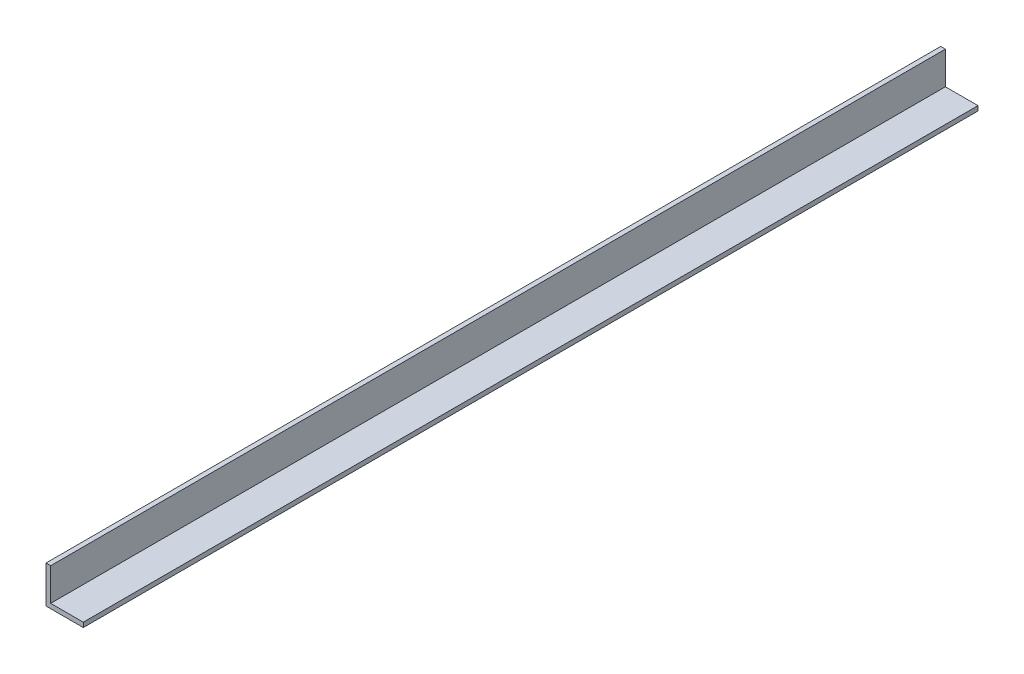
from build123d import *

# Parameters (mm, degrees)
BOSS_EXTRUDE1_DEPTH = 304.8


with BuildPart() as part:
    # Sketch1 → Boss-Extrude1 (new body, symmetric)
    with BuildSketch(Plane.XY):
        Polygon((0, 25.4), (0, 0), (25.4, 0), (25.4, 3.175), (3.175, 3.175), (3.175, 25.4), align=None)
    extrude(amount=BOSS_EXTRUDE1_DEPTH, both=True)


solid = part.part
